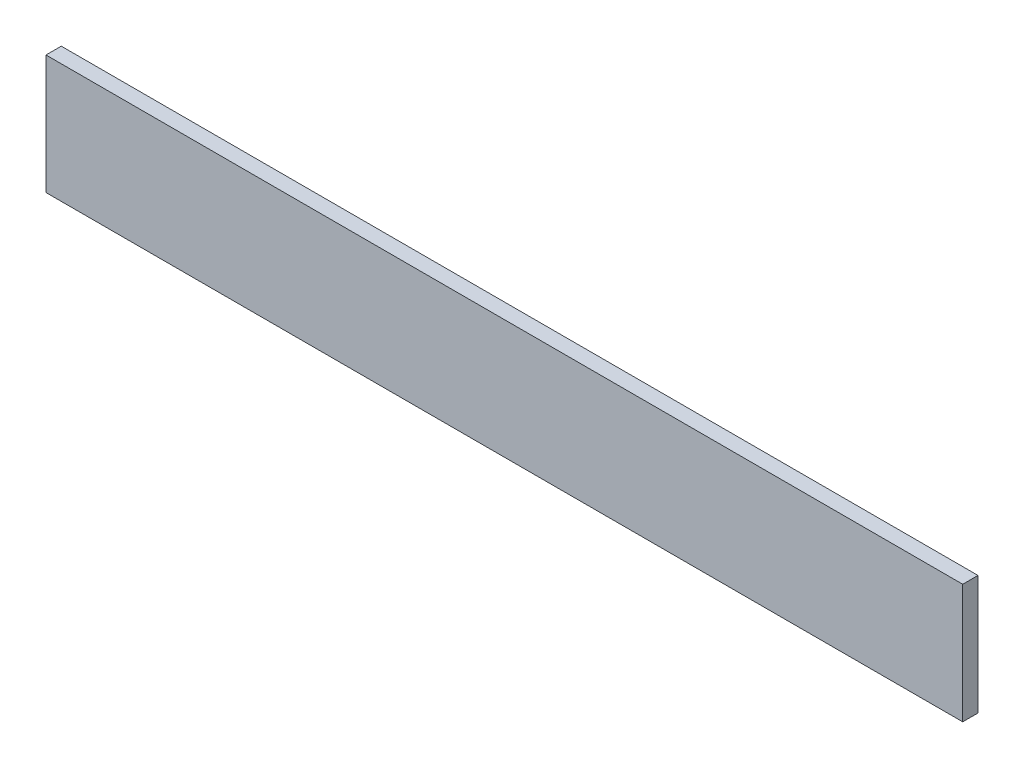
from build123d import *

# Parameters (mm, degrees)
ESQUISSE1_W        = 600
ESQUISSE1_H        = 78
BOSS_EXTRU_1_DEPTH = 10


with BuildPart() as part:
    # Esquisse1 → Boss.-Extru.1 (new body)
    with BuildSketch(Plane.XY):
        with Locations((300, 39)):
            Rectangle(ESQUISSE1_W, ESQUISSE1_H)
    extrude(amount=BOSS_EXTRU_1_DEPTH)


solid = part.part
